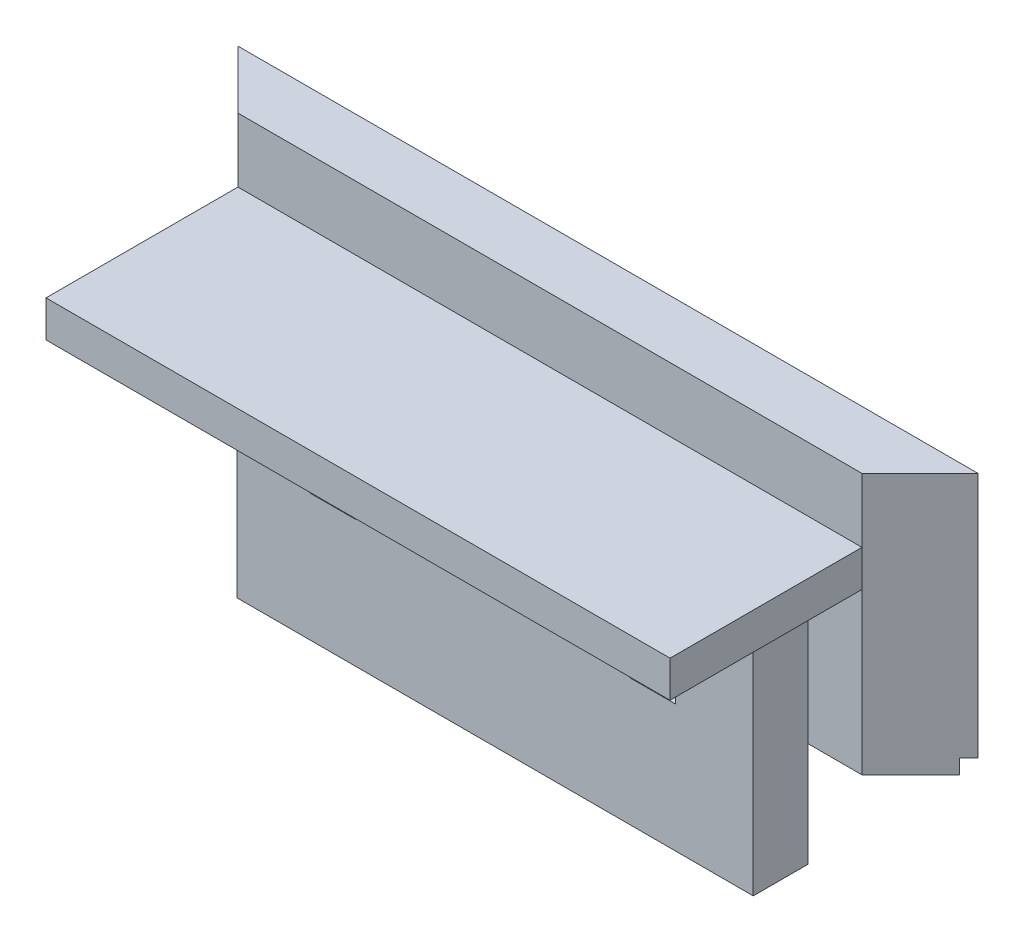
from build123d import *

# Parameters (mm, degrees)
BOSS_EXTRUDE1_DEPTH     = 28.575
SKETCH2_W               = 1.00076
SKETCH2_H               = 1.5875
CUT_EXTRUDE2_DEPTH      = 41.5003
CUT_EXTRUDE2_DEPTH_BACK = 41.5003
SKETCH3_W               = 68.3006
SKETCH3_H               = 3.9878
BOSS_EXTRUDE2_DEPTH     = 21.0058
SKETCH4_W               = 56.4896
SKETCH4_H               = 29.0068
BOSS_EXTRUDE3_DEPTH     = 5.9944
SKETCH5_W               = 5.0038
SKETCH5_H               = 15.07744
CUT_EXTRUDE3_DEPTH      = 5.9944


with BuildPart() as part:
    # Sketch1 → Boss-Extrude1 (new body)
    with BuildSketch(Plane(origin=(0, 0, 0), x_dir=(1, 0, 0), z_dir=(0, 1, 0))):
        Polygon((-40.5003, 0), (40.5003, 0), (34.1503, -6.35), (-34.1503, -6.35), align=None)
    extrude(amount=BOSS_EXTRUDE1_DEPTH)

    # Sketch2 → Cut-Extrude2 (cut, two sides)
    with BuildSketch(Plane(origin=(0, 0, 0), x_dir=(0, 0, -1), z_dir=(1, 0, 0))) as cut_extrude2_sk:
        with Locations((-0.50038, 0.79375)):
            Rectangle(SKETCH2_W, SKETCH2_H)
    extrude(amount=CUT_EXTRUDE2_DEPTH, mode=Mode.SUBTRACT)
    extrude(cut_extrude2_sk.sketch, amount=-CUT_EXTRUDE2_DEPTH_BACK, mode=Mode.SUBTRACT)

    # Sketch3 → Boss-Extrude2 (add)
    with BuildSketch(Plane.XY.offset(6.35)):
        with Locations((0, 19.5707)):
            Rectangle(SKETCH3_W, SKETCH3_H)
    extrude(amount=BOSS_EXTRUDE2_DEPTH)

    # Sketch4 → Boss-Extrude3 (add)
    with BuildSketch(Plane.XY.offset(6.35)):
        with Locations((0, 3.0734)):
            Rectangle(SKETCH4_W, SKETCH4_H)
    extrude(amount=BOSS_EXTRUDE3_DEPTH)

    # Sketch5 → Cut-Extrude3 (cut)
    with BuildSketch(Plane.XY.offset(12.3444)):
        with Locations((-17.7419, 10.03808)):
            Rectangle(SKETCH5_W, SKETCH5_H)
        with Locations((17.2593, 10.03808)):
            Rectangle(SKETCH5_W, SKETCH5_H)
    extrude(amount=-CUT_EXTRUDE3_DEPTH, mode=Mode.SUBTRACT)


solid = part.part
